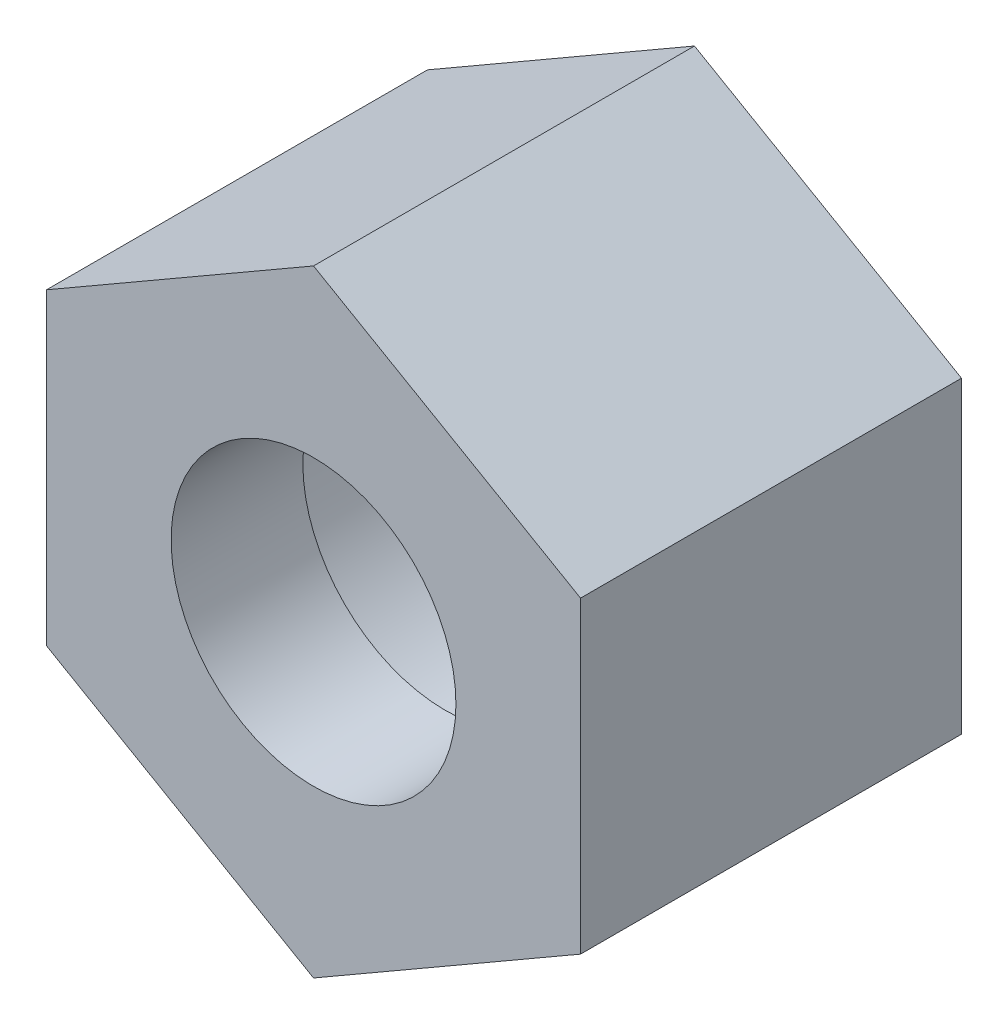
from build123d import *

# Parameters (mm, degrees)
BASE_EXTRUDE_DEPTH = 21.4
SKETCH2_R          = 11.25
CUT_EXTRUDE1_DEPTH = 14
SKETCH3_R          = 8
CUT_EXTRUDE2_DEPTH = 22.4


with BuildPart() as part:
    # Sketch1 → Base-Extrude (new body)
    with BuildSketch(Plane.XY):
        Polygon((0, 17.320508076), (-15, 8.660254038), (-15, -8.660254038), (0, -17.320508076), (15, -8.660254038), (15, 8.660254038), align=None)
    extrude(amount=BASE_EXTRUDE_DEPTH)

    # Sketch2 → Cut-Extrude1 (cut)
    with BuildSketch(Plane(origin=(0, 0, 0), x_dir=(-1, 0, 0), z_dir=(0, 0, -1))):
        Circle(SKETCH2_R)
    extrude(amount=-CUT_EXTRUDE1_DEPTH, mode=Mode.SUBTRACT)

    # Sketch3 → Cut-Extrude2 (cut, through all)
    with BuildSketch(Plane.XY.offset(21.4)):
        Circle(SKETCH3_R)
    extrude(amount=-CUT_EXTRUDE2_DEPTH, mode=Mode.SUBTRACT)


solid = part.part
